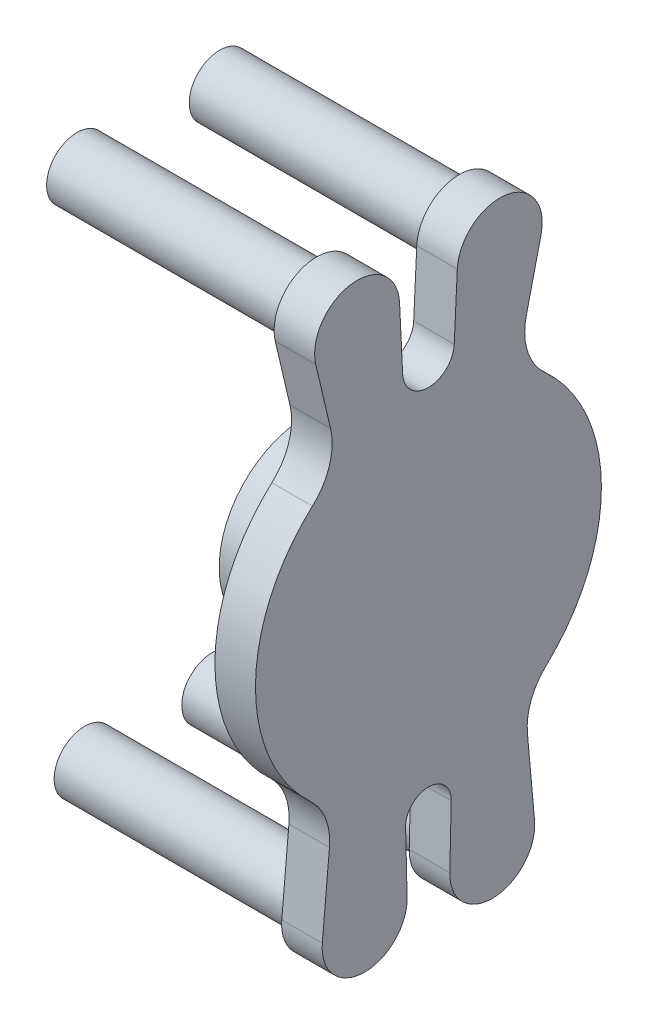
from build123d import *

# Parameters (mm, degrees)
SKETCH1_W           = 17.145
SKETCH1_H           = 18.542
SKETCH2_R           = 3.71475
CUT_EXTRUDE1_DEPTH  = 8.5725
BOSS_EXTRUDE1_DEPTH = 8.5725
SKETCH4_R           = 6.44525
SKETCH4_R_2         = 4.7474251
BOSS_EXTRUDE2_DEPTH = 50.645121951


with BuildPart() as part:
    # Sketch1 → Revolve1 (revolve)
    with BuildSketch(Plane.XY):
        with Locations((16.8275, 9.271)):
            Rectangle(SKETCH1_W, SKETCH1_H)
    revolve(axis=Axis((8.255, 0, 0), (1, 0, 0)))

    # Sketch2 → Cut-Extrude1 (cut)
    with BuildSketch(Plane.ZY.offset(-8.255)):
        Circle(SKETCH2_R)
    extrude(amount=-CUT_EXTRUDE1_DEPTH, mode=Mode.SUBTRACT)

    # Sketch3 → Boss-Extrude1 (add)
    with BuildSketch(Plane(origin=(25.4, 0, 0), x_dir=(0, 0, -1), z_dir=(1, 0, 0))):
        with BuildLine():
            Line((-20.702899344, 39.448323668), (-23.827032985, 52.708168154))
            ThreePointArc((-23.827032985, 52.708168154), (-16.334994998, 63.666100226), (-6.106605949, 55.205192121))
            Line((-6.106605949, 55.205192121), (-5.453270033, 41.770518865))
            ThreePointArc((-5.453270033, 41.770518865), (0, 36.576), (5.453270033, 41.770518865))
            Line((5.453270033, 41.770518865), (6.106605949, 55.205192121))
            ThreePointArc((6.106605949, 55.205192121), (16.334994998, 63.666100226), (23.827032985, 52.708168154))
            Line((23.827032985, 52.708168154), (20.702899344, 39.448323668))
            ThreePointArc((20.702899344, 39.448323668), (20.938893682, 32.759417922), (24.542669739, 27.119386757))
            ThreePointArc((24.542669739, 27.119386757), (36.575069792, 0.260855666), (24.926987696, -26.766566093))
            ThreePointArc((24.926987696, -26.766566093), (21.721471464, -31.520323876), (20.93336456, -37.199446597))
            Line((20.93336456, -37.199446597), (22.442795242, -53.962954235))
            ThreePointArc((22.442795242, -53.962954235), (13.789101844, -63.749144471), (4.511097805, -54.552701147))
            Line((4.511097805, -54.552701147), (4.824604712, -41.518040373))
            ThreePointArc((4.824604712, -41.518040373), (0, -36.576), (-4.824604712, -41.518040373))
            Line((-4.824604712, -41.518040373), (-4.511097805, -54.552701147))
            ThreePointArc((-4.511097805, -54.552701147), (-13.789101844, -63.749144471), (-22.442795242, -53.962954235))
            Line((-22.442795242, -53.962954235), (-20.93336456, -37.199446597))
            ThreePointArc((-20.93336456, -37.199446597), (-21.721471464, -31.520323876), (-24.926987696, -26.766566093))
            ThreePointArc((-24.926987696, -26.766566093), (-36.575069792, 0.260855666), (-24.542669739, 27.119386757))
            ThreePointArc((-24.542669739, 27.119386757), (-20.938893682, 32.759417922), (-20.702899344, 39.448323668))
        make_face()
    extrude(amount=BOSS_EXTRUDE1_DEPTH)

    # Sketch4 → Boss-Extrude2 (add)
    with BuildSketch(Plane.ZY.offset(-25.4)):
        with Locations((-15.08125, 54.76875)):
            Circle(SKETCH4_R)
        with Locations((-15.08125, 54.76875)):
            Circle(SKETCH4_R_2, mode=Mode.SUBTRACT)
        with Locations((15.08125, 54.76875)):
            Circle(SKETCH4_R)
        with Locations((15.08125, 54.76875)):
            Circle(SKETCH4_R_2, mode=Mode.SUBTRACT)
        with Locations((13.49375, -54.76875)):
            Circle(SKETCH4_R)
        with Locations((13.49375, -54.76875)):
            Circle(SKETCH4_R_2, mode=Mode.SUBTRACT)
        with Locations((-13.49375, -54.76875)):
            Circle(SKETCH4_R)
        with Locations((-13.49375, -54.76875)):
            Circle(SKETCH4_R_2, mode=Mode.SUBTRACT)
    extrude(amount=BOSS_EXTRUDE2_DEPTH)


solid = part.part
